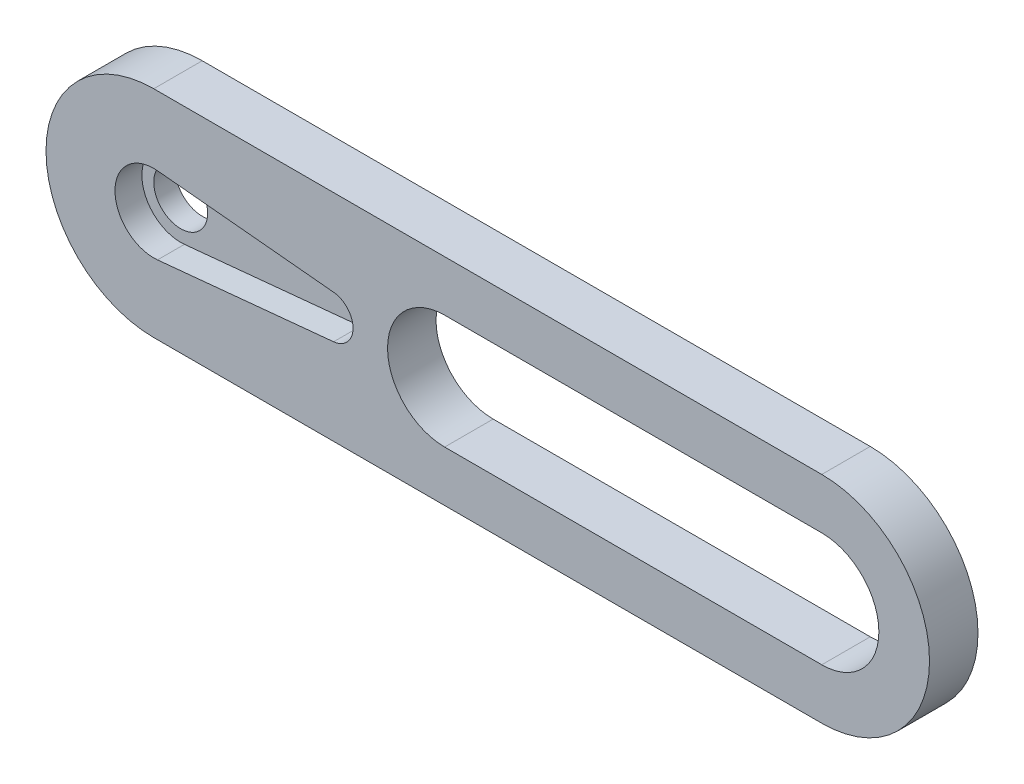
from build123d import *

# Parameters (mm, degrees)
MAIN_DEPTH            = 2.5
ESQUISSE2_R           = 2.5
ORIGINALBRACKET_DEPTH = 2
CUT_EXTRUDE1_DEPTH    = 3


with BuildPart() as part:
    # Esquisse1 → Main (new body)
    with BuildSketch(Plane.XY):
        with BuildLine():
            Line((0, 10), (62, 10))
            ThreePointArc((62, 10), (72, 0), (62, -10))
            Line((62, -10), (0, -10))
            ThreePointArc((0, -10), (-10, 0), (0, 10))
        make_face()
        with BuildLine():
            Line((0.349090909, 3.583034404), (16.693939394, 1.990574669))
            ThreePointArc((16.693939394, 1.990574669), (18.5, 0), (16.693939394, -1.990574669))
            Line((16.693939394, -1.990574669), (0.349090909, -3.583034404))
            ThreePointArc((0.349090909, -3.583034404), (-3.6, 0), (0.349090909, 3.583034404))
        make_face(mode=Mode.SUBTRACT)
        with BuildLine():
            Line((27, 5.3), (62, 5.3))
            ThreePointArc((62, 5.3), (67.3, 0), (62, -5.3))
            Line((62, -5.3), (27, -5.3))
            ThreePointArc((27, -5.3), (21.7, 0), (27, 5.3))
        make_face(mode=Mode.SUBTRACT)
    extrude(amount=MAIN_DEPTH)

    # Esquisse2 → OriginalBracket (add)
    with BuildSketch(Plane(origin=(0, 0, 0), x_dir=(-1, 0, 0), z_dir=(0, 0, -1))):
        with BuildLine():
            Line((0, -10), (-62, -10))
            ThreePointArc((-62, -10), (-72, 0), (-62, 10))
            Line((-62, 10), (0, 10))
            ThreePointArc((0, 10), (10, 0), (0, -10))
        make_face()
        Circle(ESQUISSE2_R, mode=Mode.SUBTRACT)
    extrude(amount=ORIGINALBRACKET_DEPTH)

    # Sketch1 → Cut-Extrude1 (cut, through all)
    with BuildSketch(Plane.XY):
        with BuildLine():
            Line((27, 5.3), (62, 5.3))
            ThreePointArc((62, 5.3), (67.3, 0), (62, -5.3))
            Line((62, -5.3), (27, -5.3))
            ThreePointArc((27, -5.3), (21.7, 0), (27, 5.3))
        make_face()
    extrude(amount=-CUT_EXTRUDE1_DEPTH, mode=Mode.SUBTRACT)


solid = part.part
